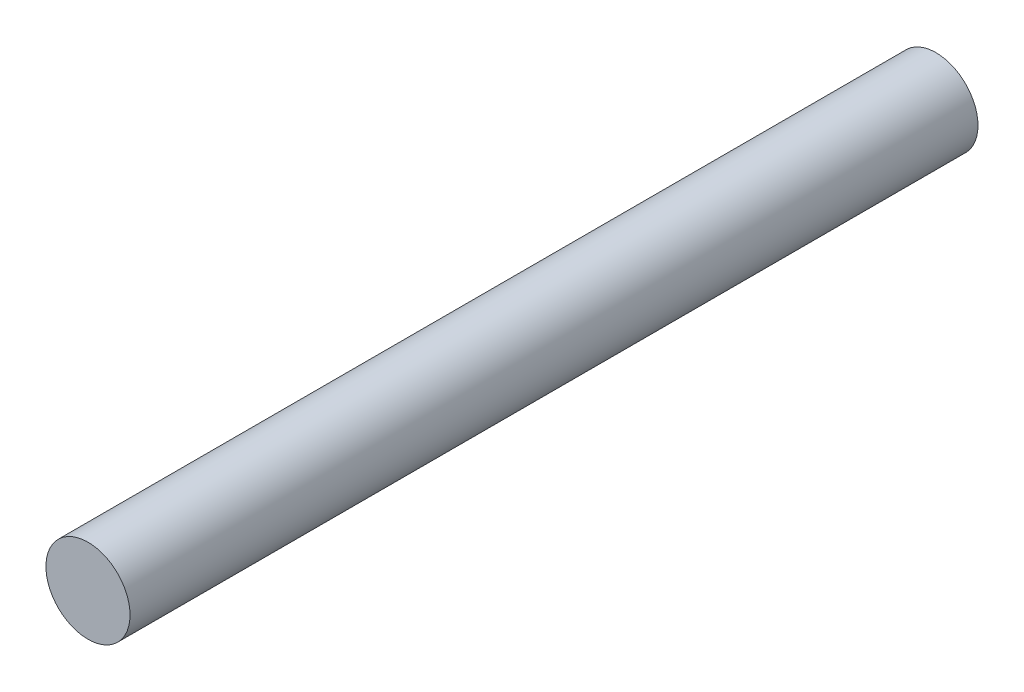
from build123d import *

# Parameters (mm, degrees)
SKETCH1_R           = 6.2
BOSS_EXTRUDE1_DEPTH = 125


with BuildPart() as part:
    # Sketch1 → Boss-Extrude1 (new body)
    with BuildSketch(Plane.XY):
        Circle(SKETCH1_R)
    extrude(amount=BOSS_EXTRUDE1_DEPTH)


solid = part.part
